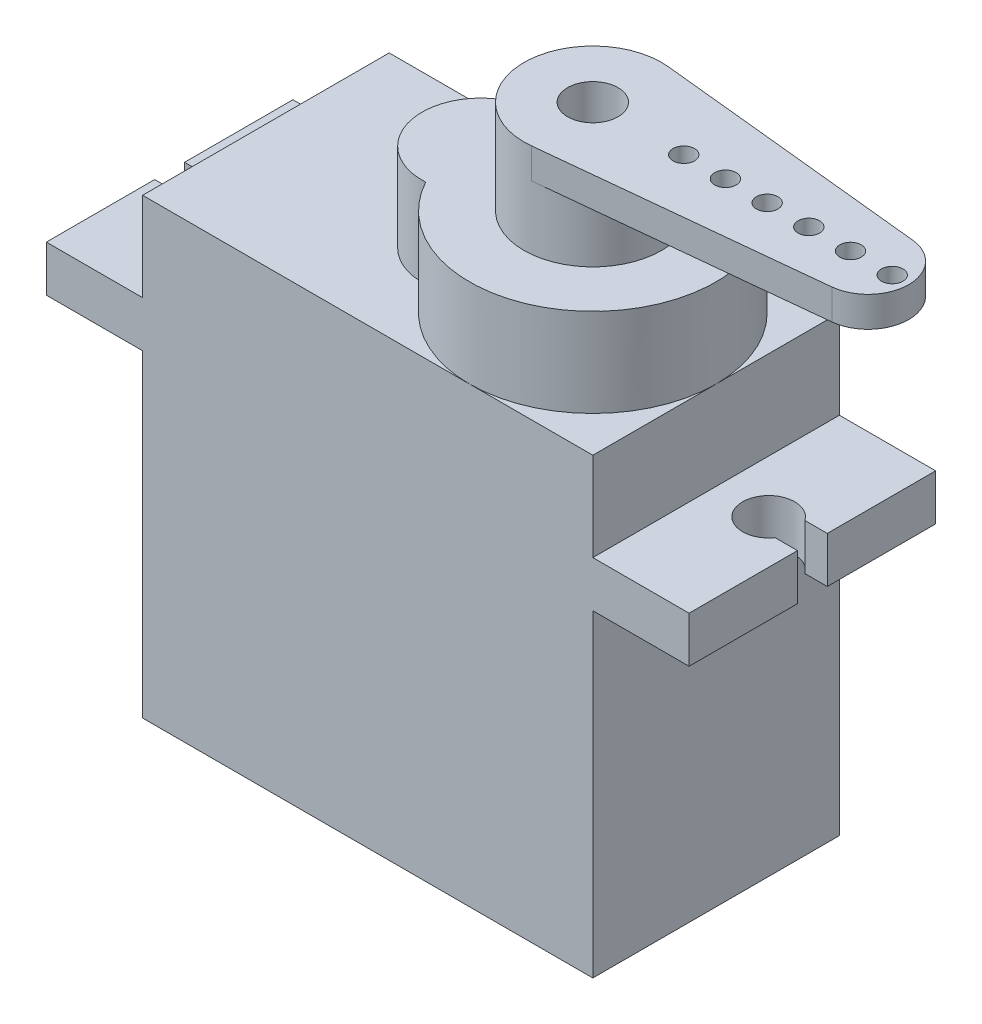
from build123d import *

# Parameters (mm, degrees)
SKETCH1_W           = 22.6314
SKETCH1_H           = 12.3952
BOSS_EXTRUDE1_DEPTH = 22.7584
BOSS_EXTRUDE2_DEPTH = 4.445
SKETCH3_R           = 3.46075
BOSS_EXTRUDE3_DEPTH = 4.7244
SKETCH4_R           = 0.53975
BOSS_EXTRUDE4_DEPTH = 1.524
BOSS_EXTRUDE5_DEPTH = 2.3114
SKETCH6_R           = 1.27
CUT_EXTRUDE1_DEPTH  = 4.7244


with BuildPart() as part:
    # Sketch1 → Boss-Extrude1 (new body)
    with BuildSketch(Plane(origin=(0, 0, 0), x_dir=(1, 0, 0), z_dir=(0, 1, 0))):
        Rectangle(SKETCH1_W, SKETCH1_H)
    extrude(amount=BOSS_EXTRUDE1_DEPTH)

    # Sketch2 → Boss-Extrude2 (add)
    with BuildSketch(Plane(origin=(0, 22.7584, 0), x_dir=(1, 0, 0), z_dir=(0, 1, 0))):
        with BuildLine():
            ThreePointArc((-0.330343341, -2.953762164), (11.3157, 0), (-0.330343341, 2.953762164))
            ThreePointArc((-0.330343341, 2.953762164), (-3.4671, 0), (-0.330343341, -2.953762164))
        make_face()
    extrude(amount=BOSS_EXTRUDE2_DEPTH)

    # Sketch3 → Boss-Extrude3 (add)
    with BuildSketch(Plane(origin=(0, 27.2034, 0), x_dir=(1, 0, 0), z_dir=(0, 1, 0))):
        with Locations((5.1181, 0)):
            Circle(SKETCH3_R)
    extrude(amount=BOSS_EXTRUDE3_DEPTH)

    # Sketch4 → Boss-Extrude4 (add)
    with BuildSketch(Plane(origin=(0, 31.9278, 0), x_dir=(1, 0, 0), z_dir=(0, 1, 0))):
        with BuildLine():
            Line((5.472274966, 3.44257907), (19.164005668, 2.033964148))
            ThreePointArc((19.164005668, 2.033964148), (20.99945, 0), (19.164005668, -2.033964148))
            Line((19.164005668, -2.033964148), (5.472274966, -3.44257907))
            ThreePointArc((5.472274966, -3.44257907), (1.65735, 0), (5.472274966, 3.44257907))
        make_face()
        with Locations((11.7856, 0)):
            Circle(SKETCH4_R, mode=Mode.SUBTRACT)
        with Locations((9.6901, 0)):
            Circle(SKETCH4_R, mode=Mode.SUBTRACT)
        with Locations((13.8811, 0)):
            Circle(SKETCH4_R, mode=Mode.SUBTRACT)
        with Locations((15.9766, 0)):
            Circle(SKETCH4_R, mode=Mode.SUBTRACT)
        with Locations((18.0721, 0)):
            Circle(SKETCH4_R, mode=Mode.SUBTRACT)
        with Locations((20.1676, 0)):
            Circle(SKETCH4_R, mode=Mode.SUBTRACT)
    extrude(amount=-BOSS_EXTRUDE4_DEPTH)

    # Sketch5 → Boss-Extrude5 (add)
    with BuildSketch(Plane(origin=(0, 18.3007, 0), x_dir=(1, 0, 0), z_dir=(0, 1, 0))):
        with BuildLine():
            Line((-16.1544, -6.1976), (16.1544, -6.1976))
            Line((16.1544, -6.1976), (16.1544, -0.7493))
            Line((16.1544, -0.7493), (15.029529043, -0.7493))
            ThreePointArc((15.029529043, -0.7493), (12.6492, 0), (15.029529043, 0.7493))
            Line((15.029529043, 0.7493), (16.1544, 0.7493))
            Line((16.1544, 0.7493), (16.1544, 6.1976))
            Line((16.1544, 6.1976), (-16.1544, 6.1976))
            Line((-16.1544, 6.1976), (-16.1544, 0.7493))
            Line((-16.1544, 0.7493), (-15.029529043, 0.7493))
            ThreePointArc((-15.029529043, 0.7493), (-12.6492, 0), (-15.029529043, -0.7493))
            Line((-15.029529043, -0.7493), (-16.1544, -0.7493))
            Line((-16.1544, -0.7493), (-16.1544, -6.1976))
        make_face()
    extrude(amount=-BOSS_EXTRUDE5_DEPTH)

    # Sketch6 → Cut-Extrude1 (cut)
    with BuildSketch(Plane(origin=(0, 31.9278, 0), x_dir=(1, 0, 0), z_dir=(0, 1, 0))):
        with Locations((5.1181, 0)):
            Circle(SKETCH6_R)
    extrude(amount=-CUT_EXTRUDE1_DEPTH, mode=Mode.SUBTRACT)


solid = part.part
